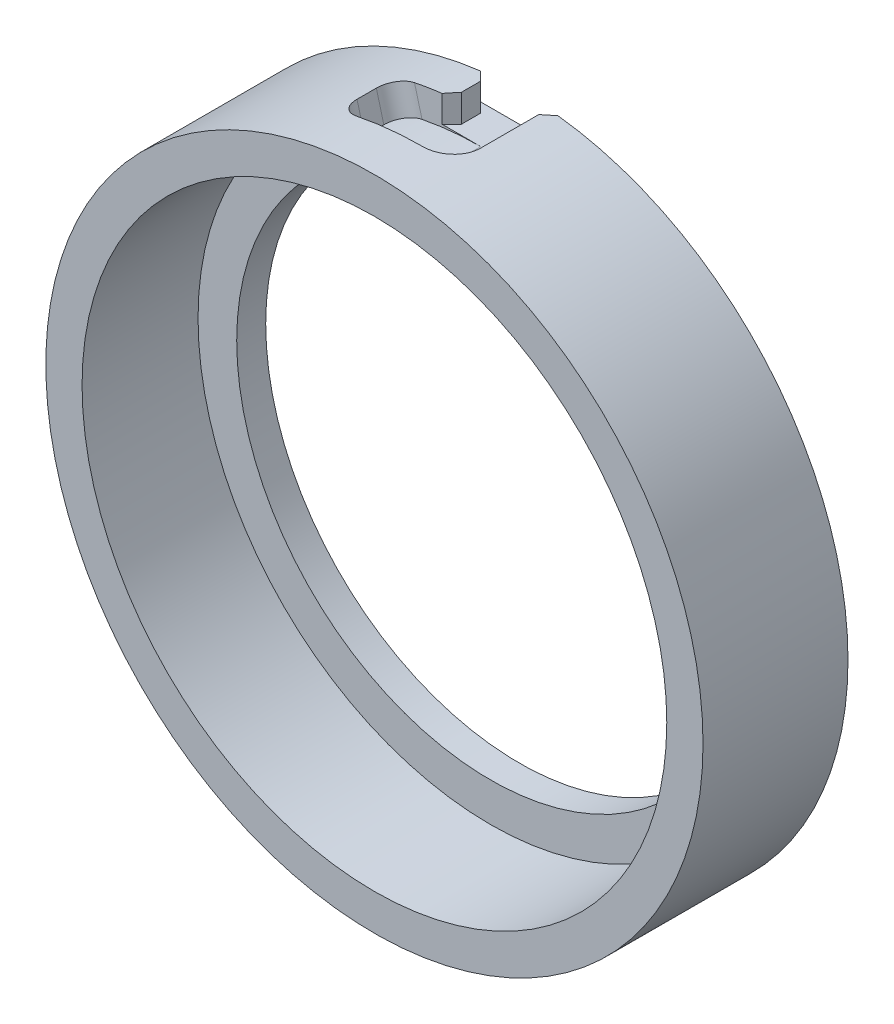
from build123d import *

# Parameters (mm, degrees)
CUT_EXTRUDE_1_DEPTH = 3
CUT_EXTRUDE_2_DEPTH = 3
CUT_REVOLVE_1_ANGLE = 15
CUT_REVOLVE_2_ANGLE = 15
CHAMFER_1_SIZE      = 1
CHAMFER_2_SIZE      = 1
FILLET_1_R          = 2
FILLET_2_R          = 2


with BuildPart() as part:
    # Эскиз2 → Повернуть1 (revolve)
    with BuildSketch(Plane(origin=(0, 0, 0), x_dir=(0, 0, -1), z_dir=(1, 0, 0))):
        Polygon((0, 30.25), (12, 30.25), (12, 26.25), (15, 26.25), (15, 34), (0, 34), align=None)
    revolve(axis=Axis((0, 0, 0), (0, 0, -1)))

    # Эскиз4 → Вырез-Вытянуть1 (cut)
    with BuildSketch(Plane(origin=(0, 34, 0), x_dir=(1, 0, 0), z_dir=(0, 1, 0))):
        with BuildLine():
            Line((3, 15), (3, 8))
            ThreePointArc((3, 8), (0, 5), (-3, 8))
            Line((-3, 8), (-3, 15))
            ThreePointArc((-3, 15), (0, 18), (3, 15))
        make_face()
    extrude(amount=-CUT_EXTRUDE_1_DEPTH, mode=Mode.SUBTRACT)

    # Эскиз5 → Вырез-Вытянуть2 (cut)
    with BuildSketch(Plane(origin=(0, -34, 0), x_dir=(-1, 0, 0), z_dir=(0, -1, 0))):
        with BuildLine():
            Line((3, 15), (3, 8))
            ThreePointArc((3, 8), (0, 5), (-3, 8))
            Line((-3, 8), (-3, 15))
            ThreePointArc((-3, 15), (0, 18), (3, 15))
        make_face()
    extrude(amount=-CUT_EXTRUDE_2_DEPTH, mode=Mode.SUBTRACT)

    # Эскиз8 → Вырез-Повернуть1 (revolve, cut)
    with BuildSketch(Plane(origin=(0, 0, 0), x_dir=(0, 0, -1), z_dir=(1, 0, 0))):
        Polygon((5, 34), (5, 31), (11, 31), (11, 34), (11, 37), (5, 37), align=None)
    revolve(axis=Axis((0, 0, 0), (0, 0, 1)), revolution_arc=CUT_REVOLVE_1_ANGLE, mode=Mode.SUBTRACT)

    # Эскиз9 → Вырез-Повернуть2 (revolve, cut)
    with BuildSketch(Plane(origin=(0, 0, 0), x_dir=(0, 0, -1), z_dir=(1, 0, 0))):
        Polygon((5, -34), (5, -31), (11, -31), (11, -34), (11, -37.830503046), (5, -37.830503046), align=None)
    revolve(axis=Axis((0, 0, 0), (0, 0, 1)), revolution_arc=CUT_REVOLVE_2_ANGLE, mode=Mode.SUBTRACT)

    # Фаска1
    chamfer_1_edges = [part.edges().sort_by_distance(p)[0] for p in [
        (3, 32.433694222, -15),
        (-3, 32.433694222, -15),
        (-3, -32.433694222, -15),
        (3, -32.433694222, -15),
    ]]
    chamfer(chamfer_1_edges, length=CHAMFER_1_SIZE)

    # Фаска2
    chamfer_2_edges = [part.edges().sort_by_distance(p)[0] for p in [
        (-3, 32.433694222, -11),
        (3, -32.433694222, -11),
    ]]
    chamfer(chamfer_2_edges, length=CHAMFER_2_SIZE)

    # Скругление1
    fillet_1_edges = [part.edges().sort_by_distance(p)[0] for p in [
        (8.411618966, -31.392589354, -5),
        (8.411618966, -31.392589354, -11),
    ]]
    fillet(fillet_1_edges, radius=FILLET_1_R)

    # Скругление2
    fillet_2_edges = [part.edges().sort_by_distance(p)[0] for p in [
        (-8.411618966, 31.392589354, -5),
        (-8.411618966, 31.392589354, -11),
    ]]
    fillet(fillet_2_edges, radius=FILLET_2_R)


solid = part.part
